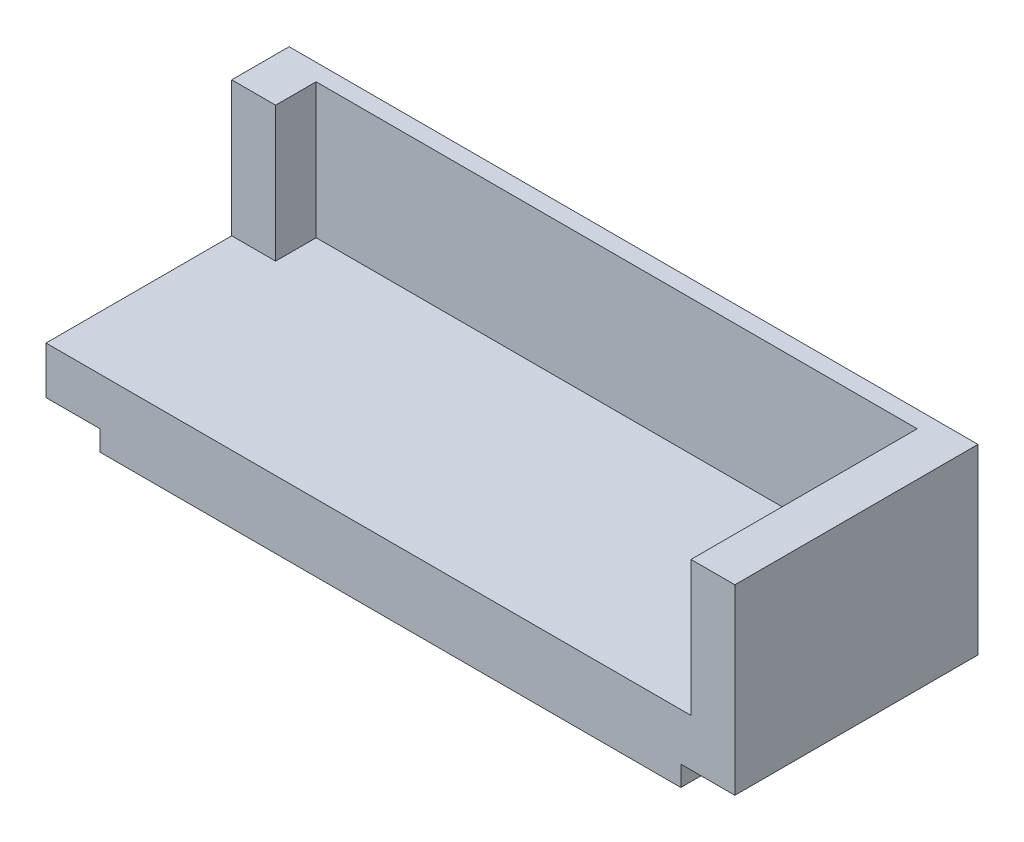
from build123d import *

# Parameters (mm, degrees)
ESQUISSE2_W             = 43
ESQUISSE2_H             = 18
BOSS_EXTRU_1_DEPTH      = 3.5
BOSS_EXTRU_1_DEPTH_BACK = 1.5
ESQUISSE3_W             = 18
ESQUISSE3_H             = 3.5
BOSS_EXTRU_2_DEPTH      = 4
ESQUISSE4_W             = 18
ESQUISSE4_H             = 3.5
BOSS_EXTRU_3_DEPTH      = 4
ESQUISSE5_W             = 51
ESQUISSE5_H             = 1.25
BOSS_EXTRU_4_DEPTH      = 10
ESQUISSE6_W             = 3.25
ESQUISSE6_H             = 16.75
BOSS_EXTRU_5_DEPTH      = 10
ESQUISSE7_W             = 3.25
ESQUISSE7_H             = 3
BOSS_EXTRU_6_DEPTH      = 10


with BuildPart() as part:
    # Esquisse2 → Boss.-Extru.1 (new body, two sides)
    with BuildSketch(Plane(origin=(0, 0, 0), x_dir=(1, 0, 0), z_dir=(0, 1, 0))) as boss_extru_1_sk:
        with Locations((21.5, 9)):
            Rectangle(ESQUISSE2_W, ESQUISSE2_H)
    extrude(amount=BOSS_EXTRU_1_DEPTH)
    extrude(boss_extru_1_sk.sketch, amount=-BOSS_EXTRU_1_DEPTH_BACK)

    # Esquisse3 → Boss.-Extru.2 (add)
    with BuildSketch(Plane(origin=(43, 0, 0), x_dir=(0, 0, -1), z_dir=(1, 0, 0))):
        with Locations((9, 1.75)):
            Rectangle(ESQUISSE3_W, ESQUISSE3_H)
    extrude(amount=BOSS_EXTRU_2_DEPTH)

    # Esquisse4 → Boss.-Extru.3 (add)
    with BuildSketch(Plane.ZY):
        with Locations((-9, 1.75)):
            Rectangle(ESQUISSE4_W, ESQUISSE4_H)
    extrude(amount=BOSS_EXTRU_3_DEPTH)

    # Esquisse5 → Boss.-Extru.4 (add)
    with BuildSketch(Plane(origin=(0, 3.5, 0), x_dir=(1, 0, 0), z_dir=(0, 1, 0))):
        with Locations((21.5, 17.375)):
            Rectangle(ESQUISSE5_W, ESQUISSE5_H)
    extrude(amount=BOSS_EXTRU_4_DEPTH)

    # Esquisse6 → Boss.-Extru.5 (add)
    with BuildSketch(Plane(origin=(0, 3.5, 0), x_dir=(1, 0, 0), z_dir=(0, 1, 0))):
        with Locations((45.375, 8.375)):
            Rectangle(ESQUISSE6_W, ESQUISSE6_H)
    extrude(amount=BOSS_EXTRU_5_DEPTH)

    # Esquisse7 → Boss.-Extru.6 (add)
    with BuildSketch(Plane(origin=(0, 3.5, 0), x_dir=(1, 0, 0), z_dir=(0, 1, 0))):
        with Locations((-2.375, 15.25)):
            Rectangle(ESQUISSE7_W, ESQUISSE7_H)
    extrude(amount=BOSS_EXTRU_6_DEPTH)


solid = part.part
